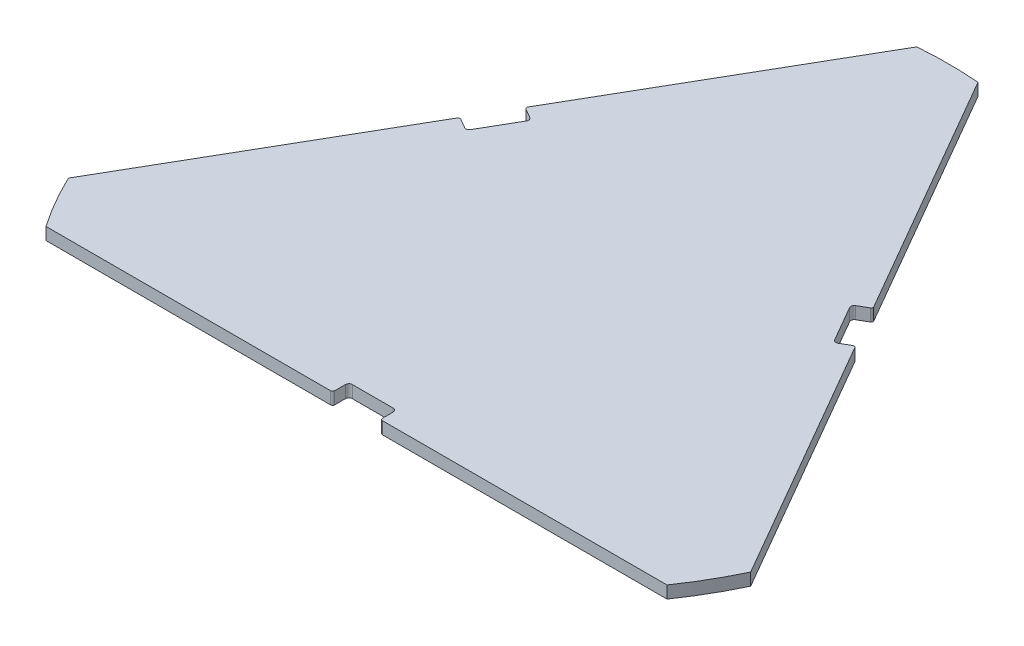
from build123d import *

# Parameters (mm, degrees)
BOSS_EXTRUDE1_DEPTH = 18
FILLET1_R           = 5


with BuildPart() as part:
    # Sketch1 → Boss-Extrude1 (new body)
    with BuildSketch(Plane(origin=(0, 0, 0), x_dir=(1, 0, 0), z_dir=(0, 1, 0))):
        with BuildLine():
            Line((-455.426852277, -314.819999892), (-38.000000187, -314.819999892))
            ThreePointArc((-38.000000187, -314.819999892), (-35.878679843, -313.941320236), (-35.000000187, -311.819999892))
            Line((-35.000000187, -311.819999892), (-35.000000187, -290.999999892))
            Line((-35.000000187, -290.999999892), (34.999999813, -290.999999892))
            Line((34.999999813, -290.999999892), (34.999999813, -311.819999892))
            ThreePointArc((34.999999813, -311.819999892), (35.87867947, -313.941320236), (37.999999813, -314.819999892))
            Line((37.999999813, -314.819999892), (455.426851904, -314.819999892))
            ThreePointArc((455.426851904, -314.819999892), (479.472561657, -276.823612404), (500.355543579, -237.001223154))
            Line((500.355543579, -237.001223154), (291.642117601, 124.501034862))
            ThreePointArc((291.642117601, 124.501034862), (289.820498525, 125.898812341), (287.54404139, 125.599111073))
            Line((287.54404139, 125.599111073), (269.513392244, 115.189110935))
            Line((269.513392244, 115.189110935), (234.513392244, 175.8108892))
            Line((234.513392244, 175.8108892), (252.544041237, 186.220889249))
            ThreePointArc((252.544041237, 186.220889249), (253.941818715, 188.042508325), (253.642117448, 190.318965461))
            Line((253.642117448, 190.318965461), (44.928691409, 551.821223582))
            ThreePointArc((44.928691409, 551.821223582), (-7e-08, 553.647225338), (-44.928691549, 551.821223601))
            Line((-44.928691549, 551.821223601), (-253.642117655, 190.318965363))
            ThreePointArc((-253.642117655, 190.318965363), (-253.941818922, 188.042508228), (-252.544041443, 186.220889153))
            Line((-252.544041443, 186.220889153), (-234.513392501, 175.810889132))
            Line((-234.513392501, 175.810889132), (-269.513392501, 115.189110868))
            Line((-269.513392501, 115.189110868), (-287.544041036, 125.599110653))
            ThreePointArc((-287.544041036, 125.599110653), (-289.820498172, 125.89881192), (-291.642117248, 124.50103444))
            Line((-291.642117248, 124.50103444), (-500.355543515, -237.001224077))
            ThreePointArc((-500.355543515, -237.001224077), (-479.472561775, -276.823612847), (-455.426852277, -314.819999892))
        make_face()
    extrude(amount=BOSS_EXTRUDE1_DEPTH)

    # Fillet1
    fillet1_edges = [part.edges().sort_by_distance(p)[0] for p in [
        (-269.513392501, 9, -115.189110868),
        (-234.513392501, 9, -175.810889132),
        (234.513392244, 9, -175.8108892),
        (269.513392244, 9, -115.189110935),
        (34.999999813, 9, 290.999999892),
        (-35.000000187, 9, 290.999999892),
    ]]
    fillet(fillet1_edges, radius=FILLET1_R)


solid = part.part
